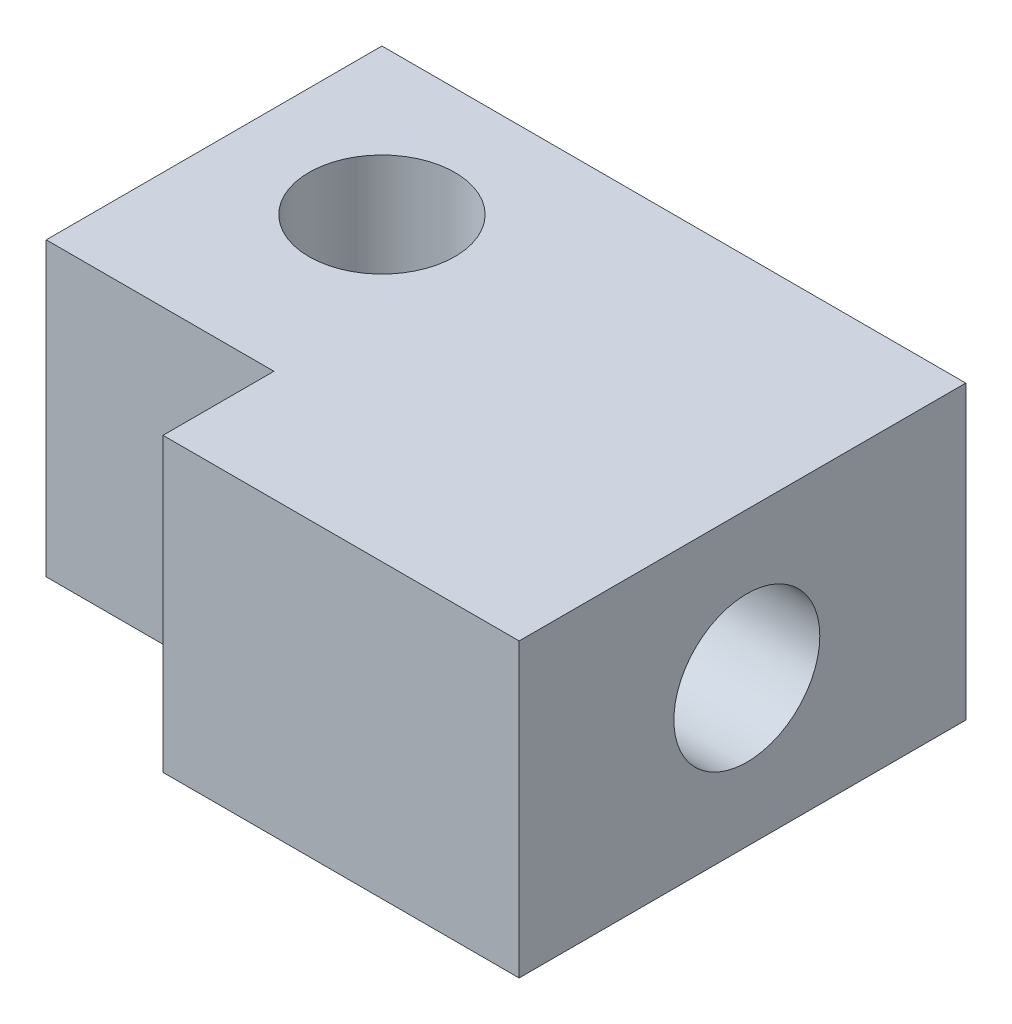
from build123d import *

# Parameters (mm, degrees)
SKETCH4_R           = 1.25
BOSS_EXTRUDE1_DEPTH = 5
CUT_EXTRUDE1_DEPTH  = 10


with BuildPart() as part:
    # Sketch4 → Boss-Extrude1 (new body)
    with BuildSketch(Plane(origin=(0, 0, 0), x_dir=(1, 0, 0), z_dir=(0, 1, 0))):
        Polygon((79, -2.5), (79, -5), (79, -7.5), (79, -8.25), (82.9, -8.25), (82.9, -10.15), (89, -10.15), (89, -2.5), align=None)
        with Locations((81.5, -5)):
            Circle(SKETCH4_R, mode=Mode.SUBTRACT)
    extrude(amount=BOSS_EXTRUDE1_DEPTH)

    # Sketch5 → Cut-Extrude1 (cut)
    with BuildSketch(Plane(origin=(89, 0, 0), x_dir=(0, 0, -1), z_dir=(1, 0, 0))):
        with BuildLine():
            ThreePointArc((-5, 2.5), (-5.366116524, 3.383883476), (-6.25, 3.75))
            Line((-6.25, 3.75), (-6.25, 1.25))
            ThreePointArc((-6.25, 1.25), (-5.366116524, 1.616116524), (-5, 2.5))
        make_face()
        with BuildLine():
            Line((-6.25, 1.25), (-6.25, 3.75))
            ThreePointArc((-6.25, 3.75), (-7.5, 2.5), (-6.25, 1.25))
        make_face()
    extrude(amount=-CUT_EXTRUDE1_DEPTH, mode=Mode.SUBTRACT)


solid = part.part
